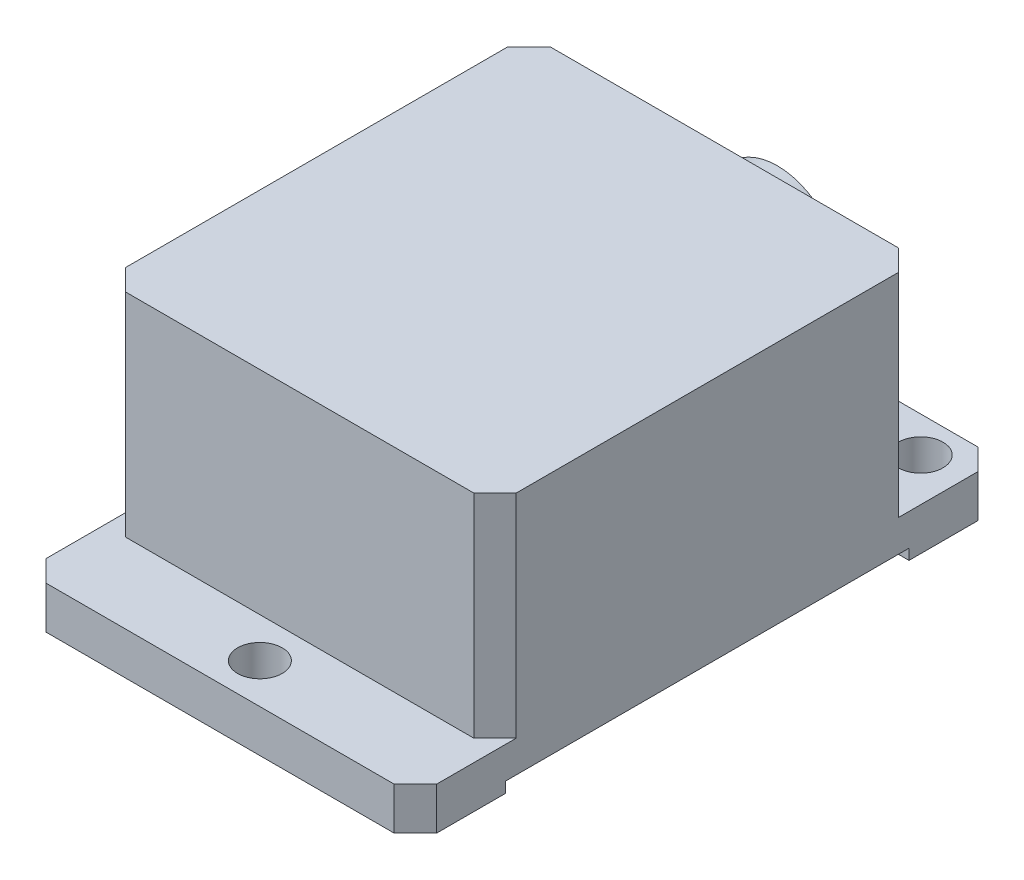
from build123d import *

# Parameters (mm, degrees)
SKETCH3_W           = 36.8
SKETCH3_H           = 55
BOSS_EXTRUDE2_DEPTH = 24
SKETCH4_W           = 38
SKETCH4_H           = 1
SKETCH4_W_2         = 7.5
SKETCH4_H_2         = 20
CUT_EXTRUDE1_DEPTH  = 37.8
SKETCH5_R           = 2.1
CUT_EXTRUDE2_DEPTH  = 5
CHAMFER1_SIZE       = 2
SKETCH6_R           = 6
BOSS_EXTRUDE3_DEPTH = 5


with BuildPart() as part:
    # Sketch3 → Boss-Extrude2 (new body)
    with BuildSketch(Plane(origin=(0, 0, 0), x_dir=(1, 0, 0), z_dir=(0, 1, 0))):
        with Locations((18.4, 27.5)):
            Rectangle(SKETCH3_W, SKETCH3_H)
    extrude(amount=BOSS_EXTRUDE2_DEPTH)

    # Sketch4 → Cut-Extrude1 (cut, through all)
    with BuildSketch(Plane(origin=(36.8, 0, 0), x_dir=(0, 0, -1), z_dir=(1, 0, 0))):
        with Locations((27.5, 0.5)):
            Rectangle(SKETCH4_W, SKETCH4_H)
        with Locations((51.25, 14)):
            Rectangle(SKETCH4_W_2, SKETCH4_H_2)
        with Locations((3.75, 14)):
            Rectangle(SKETCH4_W_2, SKETCH4_H_2)
    extrude(amount=-CUT_EXTRUDE1_DEPTH, mode=Mode.SUBTRACT)

    # Sketch5 → Cut-Extrude2 (cut, through all)
    with BuildSketch(Plane(origin=(0, 4, 0), x_dir=(1, 0, 0), z_dir=(0, 1, 0))):
        with Locations((18.4, 3.75)):
            Circle(SKETCH5_R)
        with Locations((32.75, 51.65)):
            Circle(SKETCH5_R)
        with Locations((4.05, 51.65)):
            Circle(SKETCH5_R)
    extrude(amount=-CUT_EXTRUDE2_DEPTH, mode=Mode.SUBTRACT)

    # Chamfer1
    chamfer1_edges = [part.edges().sort_by_distance(p)[0] for p in [
        (0, 2, -55),
        (36.8, 2, -55),
        (36.8, 2, 0),
        (0, 2, 0),
        (0, 14, -47.5),
        (36.8, 14, -47.5),
        (0, 14, -7.5),
        (36.8, 14, -7.5),
    ]]
    chamfer(chamfer1_edges, length=CHAMFER1_SIZE)

    # Sketch6 → Boss-Extrude3 (add)
    with BuildSketch(Plane(origin=(0, 0, -47.5), x_dir=(-1, 0, 0), z_dir=(0, 0, -1))):
        with Locations((-18.4, 14)):
            Circle(SKETCH6_R)
    extrude(amount=BOSS_EXTRUDE3_DEPTH)


solid = part.part
